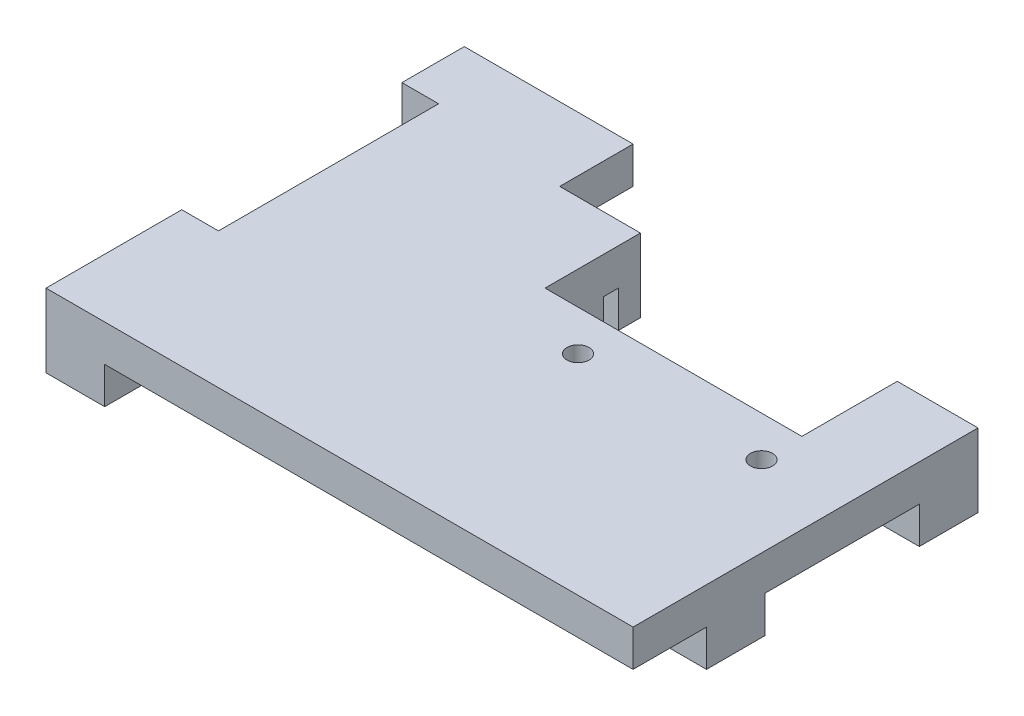
from build123d import *

# Parameters (mm, degrees)
SKETCH1_W               = 8
SKETCH1_H               = 57
SKETCH1_W_2             = 2
SKETCH1_H_2             = 51
BOSS_EXTRUDE1_DEPTH     = 5
SKETCH2_W               = 80
SKETCH2_H               = 57
BOSS_EXTRUDE2_DEPTH     = 5
SKETCH3_W               = 40
SKETCH3_H               = 10
CUT_EXTRUDE1_DEPTH      = 8
SKETCH4_W               = 57
SKETCH4_H               = 8
SKETCH4_W_2             = 51
SKETCH4_H_2             = 2
BOSS_EXTRUDE3_DEPTH     = 5
SKETCH5_W               = 35
SKETCH5_H               = 10
CUT_EXTRUDE2_DEPTH      = 8
SKETCH6_W               = 35
SKETCH6_H               = 5
CUT_EXTRUDE3_DEPTH      = 6
CUT_EXTRUDE3_DEPTH_BACK = 6
SKETCH7_W               = 30
SKETCH7_H               = 5
CUT_EXTRUDE5_DEPTH      = 5
SKETCH8_R               = 1.5
CUT_EXTRUDE6_DEPTH      = 1
CUT_EXTRUDE6_DEPTH_BACK = 11


with BuildPart() as part:
    # Sketch1 → Boss-Extrude1 (new body)
    with BuildSketch(Plane(origin=(0, 0, 0), x_dir=(1, 0, 0), z_dir=(0, 1, 0))):
        Rectangle(SKETCH1_W, SKETCH1_H)
        Rectangle(SKETCH1_W_2, SKETCH1_H_2, mode=Mode.SUBTRACT)
    extrude(amount=BOSS_EXTRUDE1_DEPTH)

    # Sketch2 → Boss-Extrude2 (add)
    with BuildSketch(Plane(origin=(0, 5, 0), x_dir=(1, 0, 0), z_dir=(0, 1, 0))):
        with Locations((36, 0)):
            Rectangle(SKETCH2_W, SKETCH2_H)
    extrude(amount=BOSS_EXTRUDE2_DEPTH)

    # Sketch3 → Cut-Extrude1 (cut)
    with BuildSketch(Plane.ZY.offset(4)):
        Rectangle(SKETCH3_W, SKETCH3_H)
    extrude(amount=-CUT_EXTRUDE1_DEPTH, mode=Mode.SUBTRACT)

    # Sketch4 → Boss-Extrude3 (add)
    with BuildSketch(Plane.XZ.offset(-5)):
        with Locations((47.5, 14.5)):
            Rectangle(SKETCH4_W, SKETCH4_H)
        with Locations((47.5, 14.5)):
            Rectangle(SKETCH4_W_2, SKETCH4_H_2, mode=Mode.SUBTRACT)
    boss_extrude3 = extrude(amount=BOSS_EXTRUDE3_DEPTH)

    # Sketch5 → Cut-Extrude2 (cut)
    with BuildSketch(Plane.XY.offset(18.5)):
        with Locations((47.5, 0)):
            Rectangle(SKETCH5_W, SKETCH5_H)
    cut_extrude2 = extrude(amount=-CUT_EXTRUDE2_DEPTH, mode=Mode.SUBTRACT)

    # Mirror2: Boss-Extrude3, Cut-Extrude2 across plane
    add(boss_extrude3.mirror(Plane.XY))
    add(cut_extrude2.mirror(Plane.XY), mode=Mode.SUBTRACT)

    # Sketch6 → Cut-Extrude3 (cut, two sides)
    with BuildSketch(Plane.XZ.offset(-5)) as cut_extrude3_sk:
        Polygon((30, -18.5), (65, -18.5), (65, -15.5), (65, -13.5), (65, -10.5), (30, -10.5), (30, -13.5), (30, -15.5), align=None)
        Polygon((19, -28.5), (76, -28.5), (76, -18.5), (65, -18.5), (30, -18.5), (19, -18.5), align=None)
        with Locations((47.5, -8)):
            Rectangle(SKETCH6_W, SKETCH6_H)
    extrude(amount=CUT_EXTRUDE3_DEPTH, mode=Mode.SUBTRACT)
    extrude(cut_extrude3_sk.sketch, amount=-CUT_EXTRUDE3_DEPTH_BACK, mode=Mode.SUBTRACT)

    # Sketch7 → Cut-Extrude5 (cut)
    with BuildSketch(Plane.ZY.offset(4)):
        with Locations((-5, 7.5)):
            Rectangle(SKETCH7_W, SKETCH7_H)
    extrude(amount=-CUT_EXTRUDE5_DEPTH, mode=Mode.SUBTRACT)

    # Sketch8 → Cut-Extrude6 (cut, two sides)
    with BuildSketch(Plane(origin=(0, 10, 0), x_dir=(1, 0, 0), z_dir=(0, 1, 0))) as cut_extrude6_sk:
        with Locations((65, 0)):
            Circle(SKETCH8_R)
        with Locations((40, 0)):
            Circle(SKETCH8_R)
    extrude(amount=CUT_EXTRUDE6_DEPTH, mode=Mode.SUBTRACT)
    extrude(cut_extrude6_sk.sketch, amount=-CUT_EXTRUDE6_DEPTH_BACK, mode=Mode.SUBTRACT)


solid = part.part
